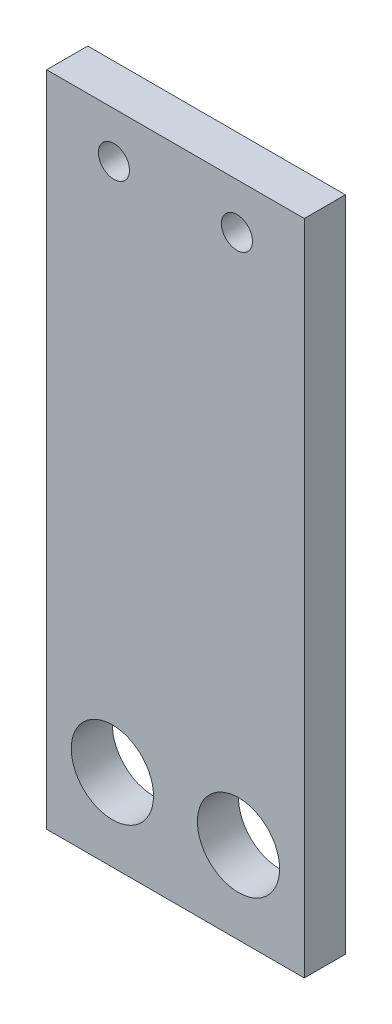
from build123d import *

# Parameters (mm, degrees)
SKETCH1_W           = 19.9
SKETCH1_H           = 50.8
SKETCH1_R           = 1.2
SKETCH1_R_2         = 3.175
BOSS_EXTRUDE1_DEPTH = 3.175


with BuildPart() as part:
    # Sketch1 → Boss-Extrude1 (new body)
    with BuildSketch(Plane.XY):
        with Locations((0.904028138, -9.696238371)):
            Rectangle(SKETCH1_W, SKETCH1_H)
        with Locations((-3.845971862, 12.17210412)):
            Circle(SKETCH1_R, mode=Mode.SUBTRACT)
        with Locations((5.654028138, 12.17210412)):
            Circle(SKETCH1_R, mode=Mode.SUBTRACT)
        with Locations((-3.965971862, -28.746238371)):
            Circle(SKETCH1_R_2, mode=Mode.SUBTRACT)
        with Locations((5.774028138, -28.746238371)):
            Circle(SKETCH1_R_2, mode=Mode.SUBTRACT)
    extrude(amount=BOSS_EXTRUDE1_DEPTH)


solid = part.part
